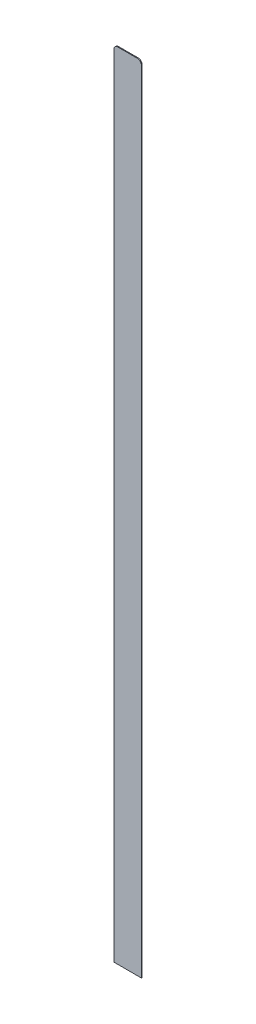
from build123d import *

# Parameters (mm, degrees)
ESBO_O1_W                = 35
ESBO_O1_H                = 1010
RESSALTO_EXTRUS_O1_DEPTH = 1
FILETE1_R                = 5


with BuildPart() as part:
    # Esboço1 → Ressalto-extrusão1 (new body)
    with BuildSketch(Plane.XY):
        with Locations((17.5, 505)):
            Rectangle(ESBO_O1_W, ESBO_O1_H)
    extrude(amount=RESSALTO_EXTRUS_O1_DEPTH)

    # Filete1
    filete1_edges = [part.edges().sort_by_distance(p)[0] for p in [
        (0, 1010, 0.5),
        (35, 1010, 0.5),
    ]]
    fillet(filete1_edges, radius=FILETE1_R)


solid = part.part
